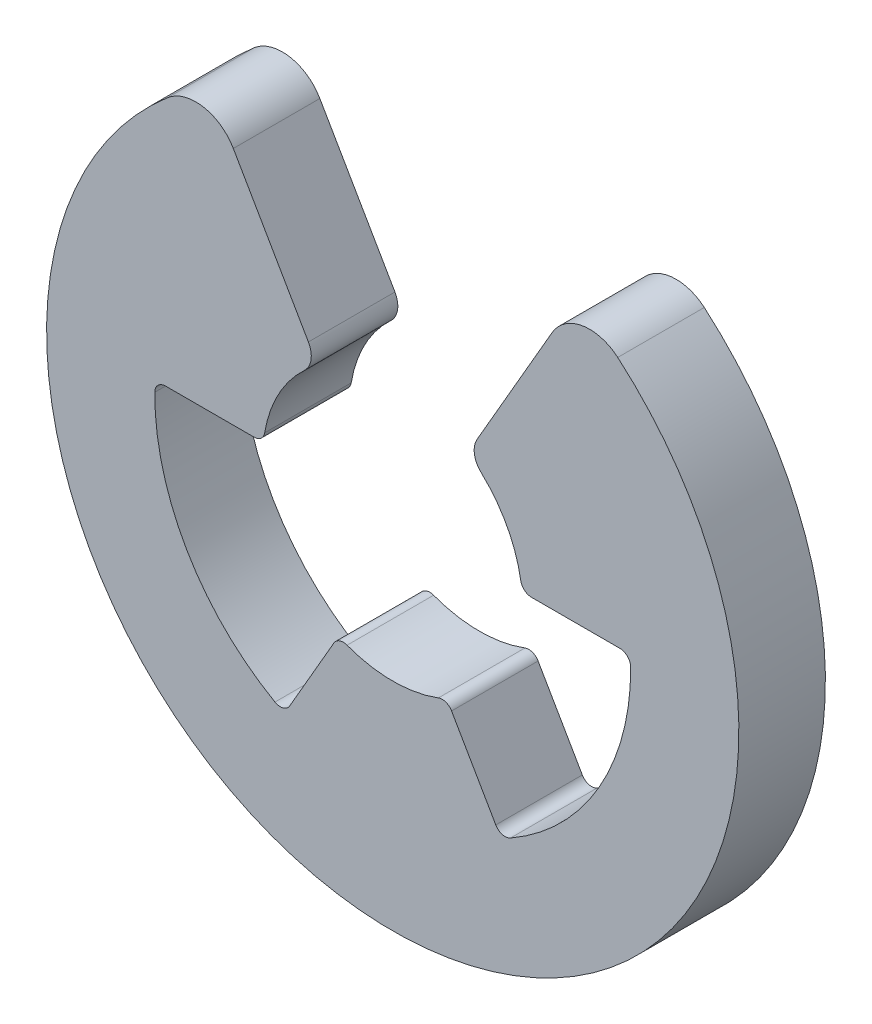
from build123d import *

# Parameters (mm, degrees)
BOSS_EXTRUDE1_DEPTH = 2


with BuildPart() as part:
    # Sketch2 → Boss-Extrude1 (new body)
    with BuildSketch(Plane.XY):
        with BuildLine():
            Line((2.381551342, -4.687082444), (1.359756513, -2.917281885))
            ThreePointArc((1.359756513, -2.917281885), (1.227533074, -2.806917507), (1.055307842, -2.808260202))
            ThreePointArc((1.055307842, -2.808260202), (0, -3), (-1.055307842, -2.808260202))
            ThreePointArc((-1.055307842, -2.808260202), (-1.227533074, -2.806917507), (-1.359756513, -2.917281885))
            Line((-1.359756513, -2.917281885), (-2.381551342, -4.687082444))
            ThreePointArc((-2.381551342, -4.687082444), (-2.532638949, -4.803371457), (-2.721774726, -4.779324465))
            ThreePointArc((-2.721774726, -4.779324465), (-4.763139721, -2.75), (-5.499903763, 0.032536177))
            ThreePointArc((-5.499903763, 0.032536177), (-5.426161181, 0.20835606), (-5.249908137, 0.28105726))
            Line((-5.249908137, 0.28105726), (-3.206318479, 0.28105726))
            ThreePointArc((-3.206318479, 0.28105726), (-3.044628404, 0.340383927), (-2.959678596, 0.490206701))
            ThreePointArc((-2.959678596, 0.490206701), (-2.64255111, 1.420184366), (-2.041957666, 2.197819122))
            ThreePointArc((-2.041957666, 2.197819122), (-1.88784416, 2.489763038), (-1.949271241, 2.814122309))
            Line((-1.949271241, 2.814122309), (-2.98980978, 4.616387925))
            Line((-2.98980978, 4.616387925), (-3.684292593, 5.819267442))
            ThreePointArc((-3.684292593, 5.819267442), (-4.381355766, 6.304889969), (-5.200363425, 6.079162791))
            ThreePointArc((-5.200363425, 6.079162791), (0, -8), (5.200363425, 6.079162791))
            ThreePointArc((5.200363425, 6.079162791), (4.381355766, 6.304889969), (3.684292593, 5.819267442))
            Line((3.684292593, 5.819267442), (2.98980978, 4.616387925))
            Line((2.98980978, 4.616387925), (1.949271241, 2.814122309))
            ThreePointArc((1.949271241, 2.814122309), (1.88784416, 2.489763038), (2.041957666, 2.197819122))
            ThreePointArc((2.041957666, 2.197819122), (2.64255111, 1.420184366), (2.959678596, 0.490206701))
            ThreePointArc((2.959678596, 0.490206701), (3.044628404, 0.340383927), (3.206318479, 0.28105726))
            Line((3.206318479, 0.28105726), (5.249908137, 0.28105726))
            ThreePointArc((5.249908137, 0.28105726), (5.426161181, 0.20835606), (5.499903763, 0.032536177))
            ThreePointArc((5.499903763, 0.032536177), (4.763139721, -2.75), (2.721774726, -4.779324465))
            ThreePointArc((2.721774726, -4.779324465), (2.532638949, -4.803371457), (2.381551342, -4.687082444))
        make_face()
    extrude(amount=BOSS_EXTRUDE1_DEPTH)


solid = part.part
